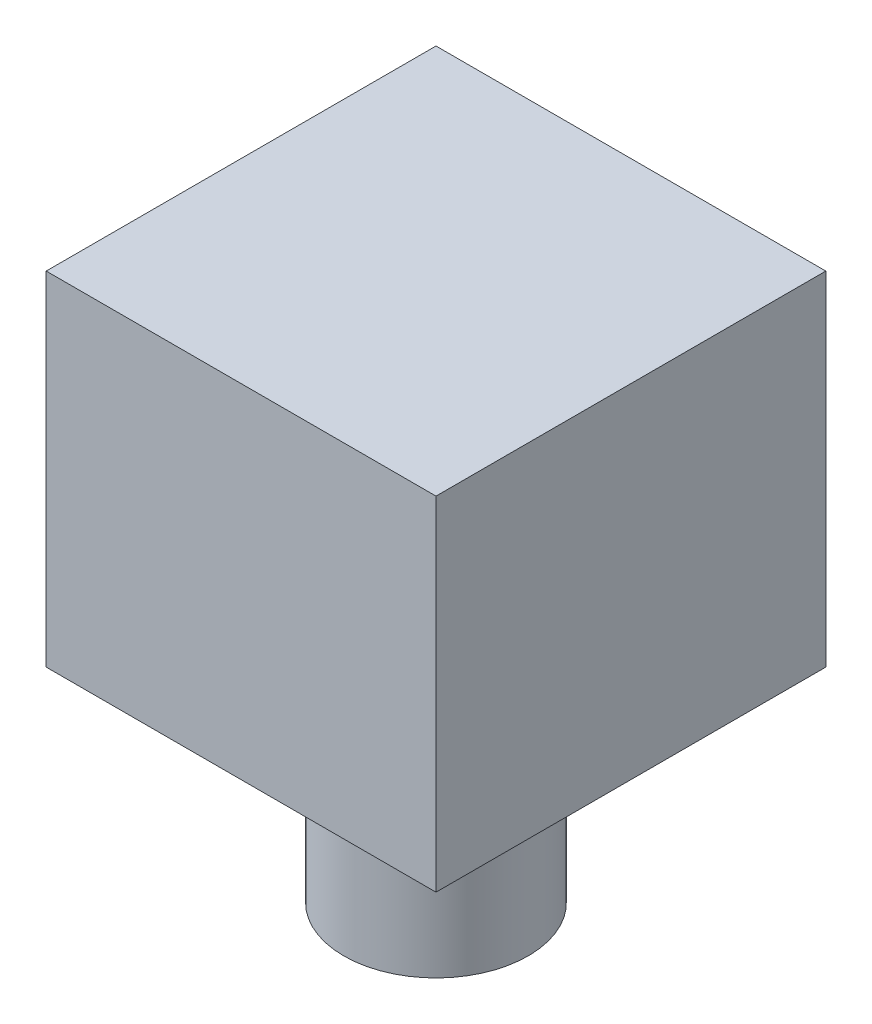
from build123d import *

# Parameters (mm, degrees)
SKETCH3_R           = 18.034
BOSS_EXTRUDE1_DEPTH = 39.878
SKETCH4_W           = 76.2
SKETCH4_H           = 76.2
BOSS_EXTRUDE2_DEPTH = 67.056


with BuildPart() as part:
    # Sketch3 → Boss-Extrude1 (new body)
    with BuildSketch(Plane(origin=(0, 0, 0), x_dir=(1, 0, 0), z_dir=(0, 1, 0))):
        Circle(SKETCH3_R)
    extrude(amount=BOSS_EXTRUDE1_DEPTH)

    # Sketch4 → Boss-Extrude2 (add)
    with BuildSketch(Plane(origin=(0, 39.878, 0), x_dir=(1, 0, 0), z_dir=(0, 1, 0))):
        Rectangle(SKETCH4_W, SKETCH4_H)
    extrude(amount=BOSS_EXTRUDE2_DEPTH)


solid = part.part
